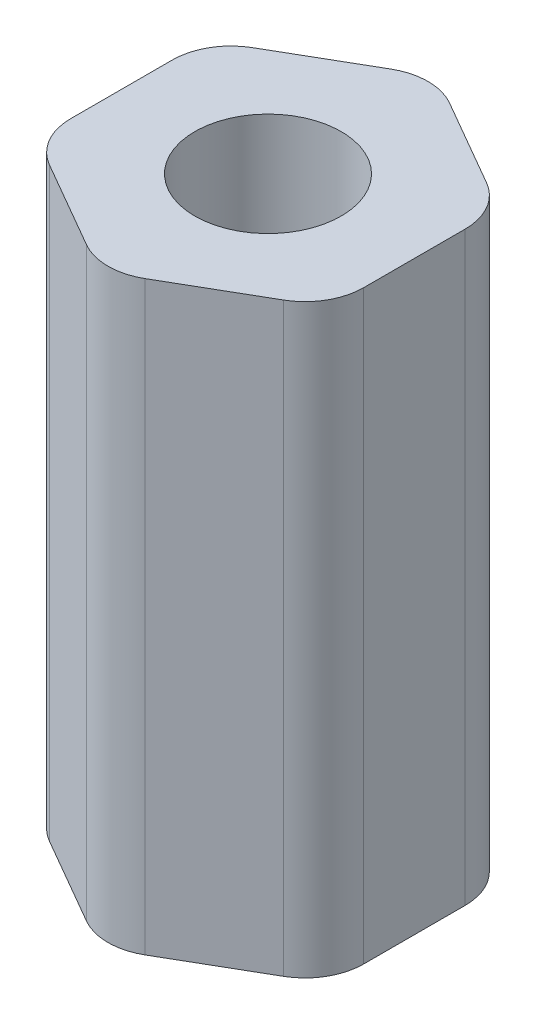
from build123d import *

# Parameters (mm, degrees)
SKETCH1_R           = 3.175
BOSS_EXTRUDE1_DEPTH = 25.4
FILLET1_R           = 2.54


with BuildPart() as part:
    # Sketch1 → Boss-Extrude1 (new body)
    with BuildSketch(Plane(origin=(0, 0, 0), x_dir=(1, 0, 0), z_dir=(0, 1, 0))):
        Polygon((6.35, -3.666174209), (6.35, 3.666174209), (0, 7.332348419), (-6.35, 3.666174209), (-6.35, -3.666174209), (0, -7.332348419), align=None)
        Circle(SKETCH1_R, mode=Mode.SUBTRACT)
    extrude(amount=BOSS_EXTRUDE1_DEPTH)

    # Fillet1
    fillet1_edges = [part.edges().sort_by_distance(p)[0] for p in [
        (0, 12.7, 7.332348419),
        (-6.35, 12.7, 3.666174209),
        (-6.35, 12.7, -3.666174209),
        (0, 12.7, -7.332348419),
        (6.35, 12.7, -3.666174209),
        (6.35, 12.7, 3.666174209),
    ]]
    fillet(fillet1_edges, radius=FILLET1_R)


solid = part.part
